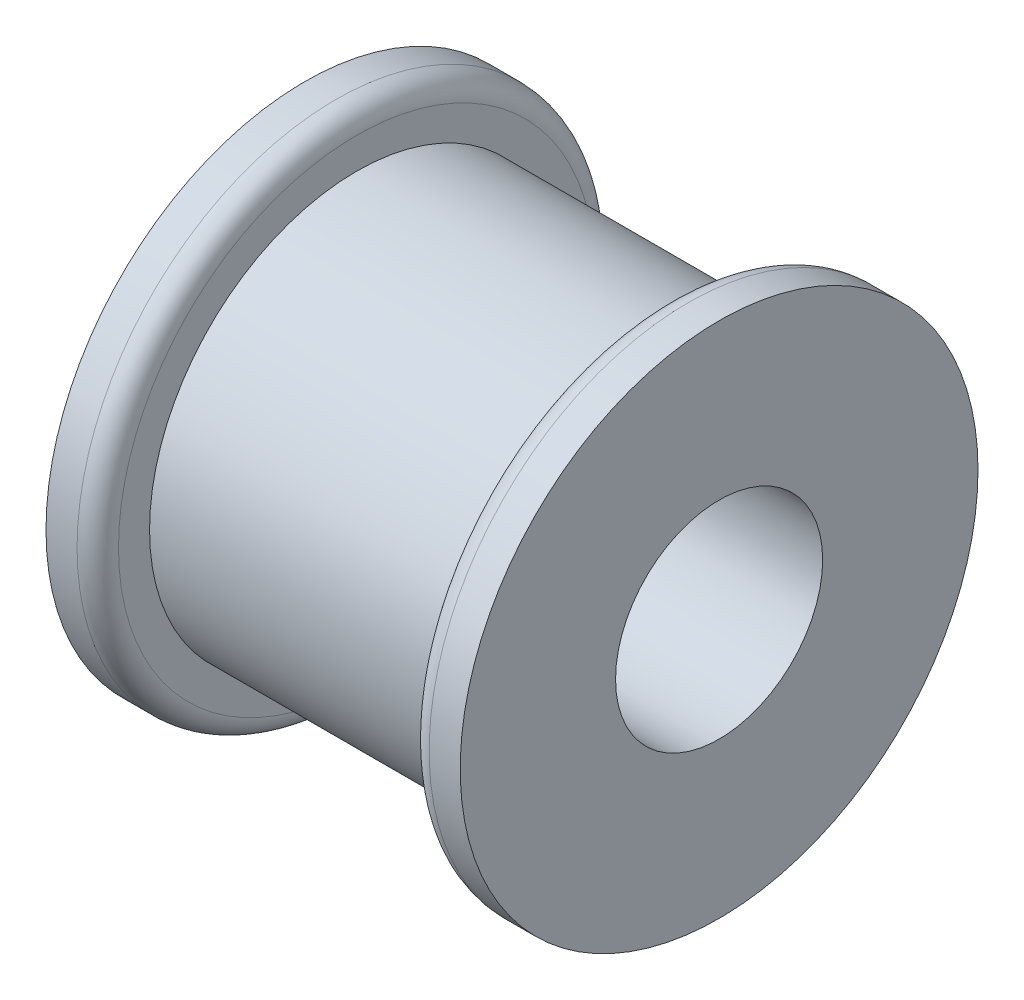
from build123d import *

# Parameters (mm, degrees)
SKETCH1_R           = 12.7
BOSS_EXTRUDE1_DEPTH = 19.05
SKETCH2_R           = 15.875
BOSS_EXTRUDE2_DEPTH = 3.175
SKETCH3_R           = 15.875
BOSS_EXTRUDE3_DEPTH = 3.175
SKETCH4_R           = 6.35
CUT_EXTRUDE1_DEPTH  = 26.4
FILLET1_R           = 1.27


with BuildPart() as part:
    # Sketch1 → Boss-Extrude1 (new body)
    with BuildSketch(Plane(origin=(0, 0, 0), x_dir=(0, 0, -1), z_dir=(1, 0, 0))):
        Circle(SKETCH1_R)
    extrude(amount=BOSS_EXTRUDE1_DEPTH)

    # Sketch2 → Boss-Extrude2 (add)
    with BuildSketch(Plane.ZY):
        Circle(SKETCH2_R)
    extrude(amount=BOSS_EXTRUDE2_DEPTH)

    # Sketch3 → Boss-Extrude3 (add)
    with BuildSketch(Plane(origin=(19.05, 0, 0), x_dir=(0, 0, -1), z_dir=(1, 0, 0))):
        Circle(SKETCH3_R)
    extrude(amount=BOSS_EXTRUDE3_DEPTH)

    # Sketch4 → Cut-Extrude1 (cut, through all)
    with BuildSketch(Plane.ZY.offset(3.175)):
        Circle(SKETCH4_R)
    extrude(amount=-CUT_EXTRUDE1_DEPTH, mode=Mode.SUBTRACT)

    # Fillet1
    fillet1_edges = [part.edges().sort_by_distance(p)[0] for p in [
        (0, 0, -15.875),
        (19.05, 0, 15.875),
    ]]
    fillet(fillet1_edges, radius=FILLET1_R)


solid = part.part
